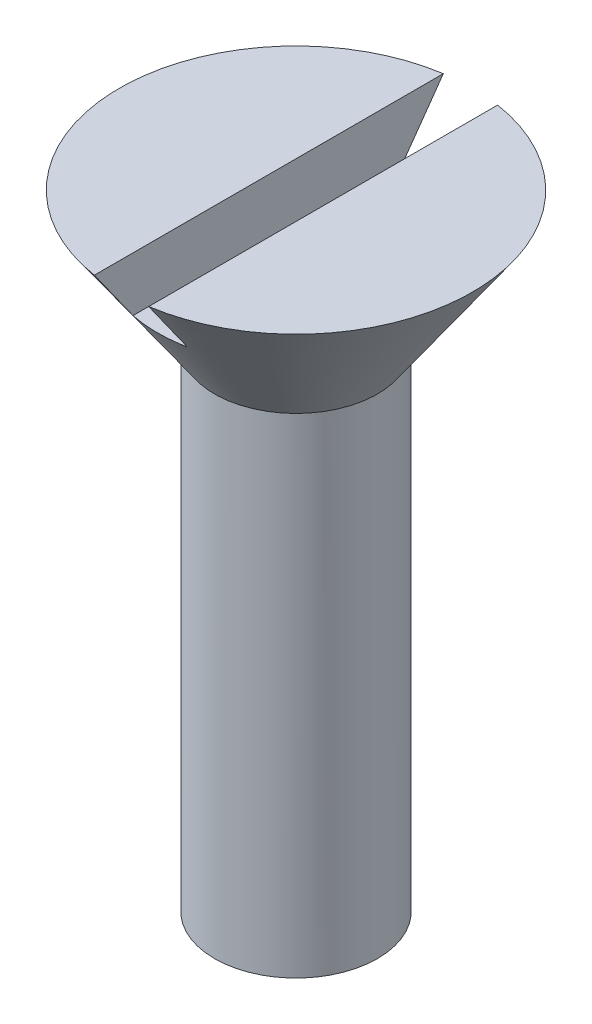
from build123d import *

# Parameters (mm, degrees)
SKETCH4_W               = 2
SKETCH4_H               = 3
CUT_EXTRUDE1_DEPTH      = 7.5
CUT_EXTRUDE1_DEPTH_BACK = 7.5


with BuildPart() as part:
    # Sketch3 → Revolve1 (revolve)
    with BuildSketch(Plane.XY):
        Polygon((0, 0), (3, 1.732050808), (3, 19.732050808), (6.5, 24.732050808), (0, 24.732050808), align=None)
    revolve(axis=Axis((0, -8.000817712, 0), (0, 1, 0)))

    # Sketch4 → Cut-Extrude1 (cut, two sides)
    with BuildSketch(Plane.XY) as cut_extrude1_sk:
        with Locations((0, 24.232050808)):
            Rectangle(SKETCH4_W, SKETCH4_H)
    extrude(amount=CUT_EXTRUDE1_DEPTH, mode=Mode.SUBTRACT)
    extrude(cut_extrude1_sk.sketch, amount=-CUT_EXTRUDE1_DEPTH_BACK, mode=Mode.SUBTRACT)


solid = part.part
